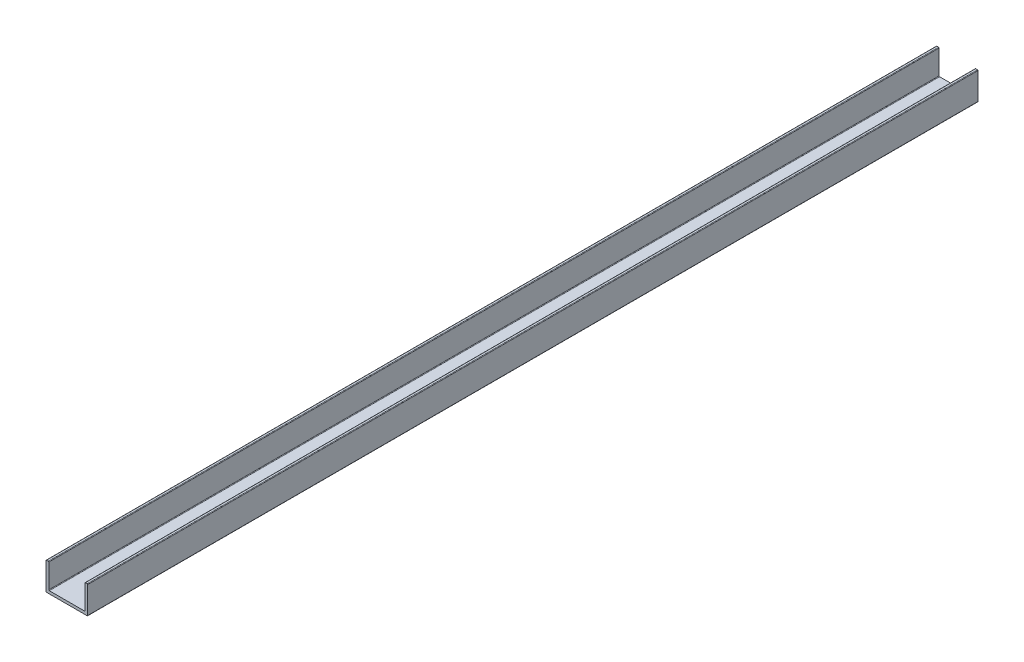
from build123d import *

# Parameters (mm, degrees)
EXTRUDE_1_DEPTH = 320


with BuildPart() as part:
    # Sketch 400 → Бобышка-Вытянуть1 (new body)
    with BuildSketch(Plane.XY):
        with BuildLine():
            Line((0, 0.2), (0, 9.8))
            ThreePointArc((0, 9.8), (0.058578644, 9.941421356), (0.2, 10))
            Line((0.2, 10), (0.8, 10))
            ThreePointArc((0.8, 10), (0.941421356, 9.941421356), (1, 9.8))
            Line((1, 9.8), (1, 1.2))
            ThreePointArc((1, 1.2), (1.058578644, 1.058578644), (1.2, 1))
            Line((1.2, 1), (13.8, 1))
            ThreePointArc((13.8, 1), (13.941421356, 1.058578644), (14, 1.2))
            Line((14, 1.2), (14, 9.8))
            ThreePointArc((14, 9.8), (14.058578644, 9.941421356), (14.2, 10))
            Line((14.2, 10), (14.8, 10))
            ThreePointArc((14.8, 10), (14.941421356, 9.941421356), (15, 9.8))
            Line((15, 9.8), (15, 0.2))
            ThreePointArc((15, 0.2), (14.941421356, 0.058578644), (14.8, 0))
            Line((14.8, 0), (0.2, 0))
            ThreePointArc((0.2, 0), (0.058578644, 0.058578644), (0, 0.2))
        make_face()
    extrude(amount=EXTRUDE_1_DEPTH)


solid = part.part
